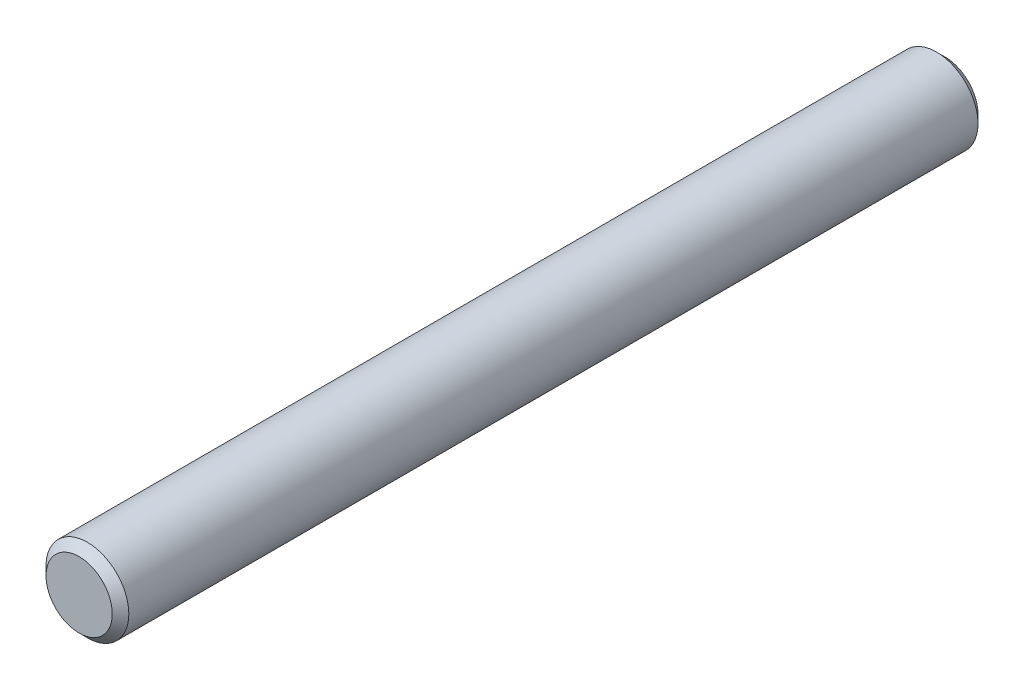
from build123d import *

# Parameters (mm, degrees)
SKETCH1_R      = 4.7625
EXTRUDE1_DEPTH = 49.784
CHAMFER1_SIZE  = 0.9525


with BuildPart() as part:
    # Sketch1 → Extrude1 (new body, symmetric)
    with BuildSketch(Plane.XY):
        Circle(SKETCH1_R)
    extrude(amount=EXTRUDE1_DEPTH, both=True)

    # Chamfer1
    chamfer1_edges = [part.edges().sort_by_distance(p)[0] for p in [
        (-4.7625, 0, -49.784),
        (-4.7625, 0, 49.784),
    ]]
    chamfer(chamfer1_edges, length=CHAMFER1_SIZE)


solid = part.part
